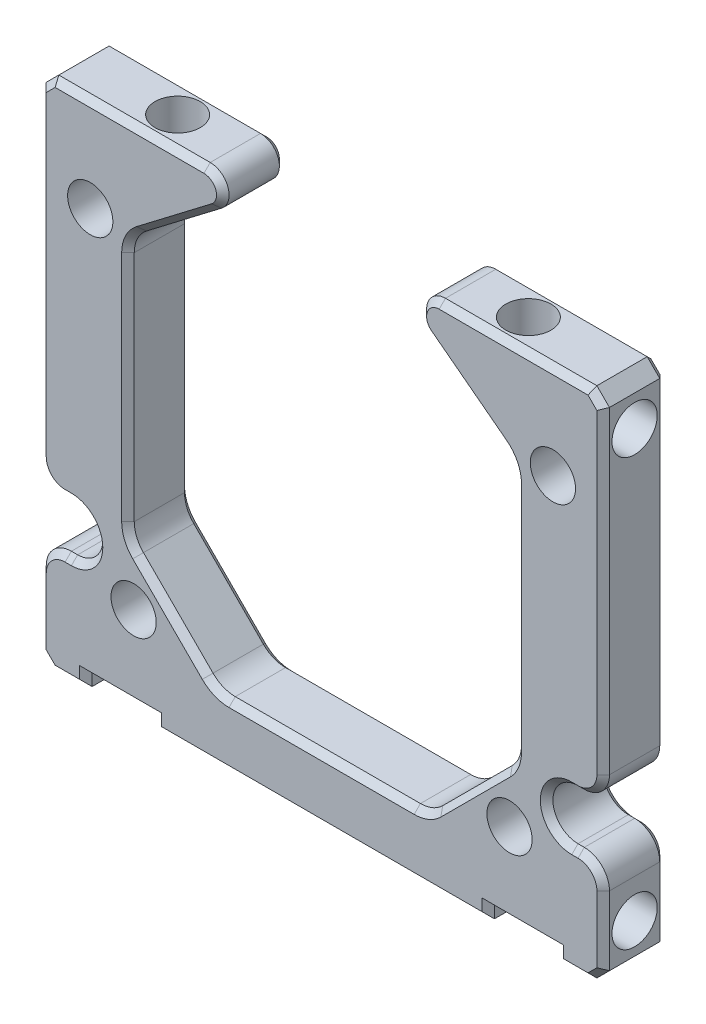
from build123d import *

# Parameters (mm, degrees)
SKETCH2_W               = 44.8
SKETCH2_H               = 40.8
SKETCH2_W_2             = 30.8
SKETCH2_H_2             = 30.8
BOSS_EXTRUDE1_DEPTH     = 5
CHAMFER1_SIZE           = 1
CHAMFER2_SIZE           = 7
SKETCH3_R               = 1.8
CUT_EXTRUDE1_DEPTH      = 31.707002459
SKETCH4_R               = 1.8
CUT_EXTRUDE2_DEPTH      = 5
SKETCH5_R               = 1.8
CUT_EXTRUDE3_DEPTH      = 5
MIRROR2_COPY_1_SKETCH_R = 1.8
MIRROR2_COPY_1_DEPTH    = 31.707002459
MIRROR2_COPY_2_SKETCH_R = 1.8
MIRROR2_COPY_2_DEPTH    = 5
SKETCH8_R               = 1.8
BOSS_EXTRUDE2_DEPTH     = 5
SKETCH9_R               = 1.8
CUT_EXTRUDE6_DEPTH      = 31.707002459
CUT_EXTRUDE4_DEPTH      = 31.707002459
FILLET2_R               = 2
CUT_EXTRUDE5_DEPTH      = 31.707002459
SKETCH10_W              = 5.5
SKETCH10_H              = 0.95
CUT_EXTRUDE7_DEPTH      = 31.707002459
FILLET3_R               = 2.5
FILLET4_R               = 1.5
CHAMFER3_SIZE           = 0.5


with BuildPart() as part:
    # Sketch2 → Boss-Extrude1 (new body)
    with BuildSketch(Plane.XY):
        Rectangle(SKETCH2_W, SKETCH2_H)
        Rectangle(SKETCH2_W_2, SKETCH2_H_2, mode=Mode.SUBTRACT)
    extrude(amount=BOSS_EXTRUDE1_DEPTH)

    # Chamfer1
    chamfer1_edges = [part.edges().sort_by_distance(p)[0] for p in [
        (-22.4, 20.4, 2.5),
        (22.4, 20.4, 2.5),
        (22.4, -20.4, 2.5),
        (-22.4, -20.4, 2.5),
    ]]
    chamfer(chamfer1_edges, length=CHAMFER1_SIZE)

    # Chamfer2
    chamfer2_edges = [part.edges().sort_by_distance(p)[0] for p in [
        (-15.4, 15.4, 2.5),
        (-15.4, -15.4, 2.5),
        (15.4, -15.4, 2.5),
        (15.4, 15.4, 2.5),
    ]]
    chamfer(chamfer2_edges, length=CHAMFER2_SIZE)

    # Sketch3 → Cut-Extrude1 (cut, through all)
    with BuildSketch(Plane.XY.offset(5)):
        with Locations((14.95, 12.95)):
            Circle(SKETCH3_R)
    cut_extrude1 = extrude(amount=-CUT_EXTRUDE1_DEPTH, mode=Mode.SUBTRACT)

    # Sketch4 → Cut-Extrude2 (cut)
    with BuildSketch(Plane(origin=(0, 20.4, 0), x_dir=(1, 0, 0), z_dir=(0, 1, 0))):
        with Locations(Location((13.95, -2.5, 0), (0, 0, 270))):
            Circle(SKETCH4_R)
    cut_extrude2 = extrude(amount=-CUT_EXTRUDE2_DEPTH, mode=Mode.SUBTRACT)

    # Sketch5 → Cut-Extrude3 (cut)
    with BuildSketch(Plane(origin=(22.4, 0, 0), x_dir=(0, 0, -1), z_dir=(1, 0, 0))):
        with Locations(Location((-2.5, 16.95, 0), (0, 0, 90))):
            Circle(SKETCH5_R)
    cut_extrude3 = extrude(amount=-CUT_EXTRUDE3_DEPTH, mode=Mode.SUBTRACT)

    # Mirror1: Cut-Extrude1, Cut-Extrude3 across plane
    add(cut_extrude1.mirror(Plane.ZX), mode=Mode.SUBTRACT)
    add(cut_extrude3.mirror(Plane.ZX), mode=Mode.SUBTRACT)

    # Mirror2: Cut-Extrude1, Cut-Extrude2, Cut-Extrude3 across plane
    add(cut_extrude1.mirror(Plane(origin=(0, 0, 0), x_dir=(0, 0, 1), z_dir=(1, 0, 0))), mode=Mode.SUBTRACT)
    add(cut_extrude2.mirror(Plane(origin=(0, 0, 0), x_dir=(0, 0, 1), z_dir=(1, 0, 0))), mode=Mode.SUBTRACT)
    add(cut_extrude3.mirror(Plane(origin=(0, 0, 0), x_dir=(0, 0, 1), z_dir=(1, 0, 0))), mode=Mode.SUBTRACT)

    # Mirror2 copy 1 sketch → Mirror2 copy 1 (cut, through all)
    with BuildSketch(Plane(origin=(0, 0, 5), x_dir=(-1, 0, 0), z_dir=(0, 0, 1))):
        with Locations((14.95, 12.95)):
            Circle(MIRROR2_COPY_1_SKETCH_R)
    extrude(amount=-MIRROR2_COPY_1_DEPTH, mode=Mode.SUBTRACT)

    # Mirror2 copy 2 sketch → Mirror2 copy 2 (cut)
    with BuildSketch(Plane(origin=(-22.4, 0, 0), x_dir=(0, 0, -1), z_dir=(-1, 0, 0))):
        with Locations(Location((-2.5, 16.95, 0), (0, 0, 90))):
            Circle(MIRROR2_COPY_2_SKETCH_R)
    extrude(amount=-MIRROR2_COPY_2_DEPTH, mode=Mode.SUBTRACT)

    # Sketch8 → Boss-Extrude2 (add)
    with BuildSketch(Plane.XY.offset(5)):
        with Locations((14.95, 12.95)):
            Circle(SKETCH8_R)
        with Locations((-14.95, 12.95)):
            Circle(SKETCH8_R)
    extrude(amount=-BOSS_EXTRUDE2_DEPTH)

    # Sketch9 → Cut-Extrude6 (cut, through all)
    with BuildSketch(Plane.XY.offset(5)):
        with Locations((18.4, 12.95)):
            Circle(SKETCH9_R)
        with Locations((-18.4, 12.95)):
            Circle(SKETCH9_R)
    extrude(amount=-CUT_EXTRUDE6_DEPTH, mode=Mode.SUBTRACT)

    # Sketch6 → Cut-Extrude4 (cut, through all)
    with BuildSketch(Plane.XY.offset(5)):
        with BuildLine():
            Line((22.4, -7.9), (19.9, -7.9))
            ThreePointArc((19.9, -7.9), (17.9, -9.9), (19.9, -11.9))
            Line((19.9, -11.9), (22.4, -11.9))
            Line((22.4, -11.9), (22.4, -7.9))
        make_face()
        with BuildLine():
            Line((-22.4, -11.9), (-19.9, -11.9))
            ThreePointArc((-19.9, -11.9), (-17.9, -9.9), (-19.9, -7.9))
            Line((-19.9, -7.9), (-22.4, -7.9))
            Line((-22.4, -7.9), (-22.4, -11.9))
        make_face()
    extrude(amount=-CUT_EXTRUDE4_DEPTH, mode=Mode.SUBTRACT)

    # Fillet2
    fillet2_edges = [part.edges().sort_by_distance(p)[0] for p in [
        (-22.4, -11.9, 2.5),
        (-22.4, -7.9, 2.5),
        (22.4, -7.9, 2.5),
        (22.4, -11.9, 2.5),
    ]]
    fillet(fillet2_edges, radius=FILLET2_R)

    # Sketch7 → Cut-Extrude5 (cut, through all)
    with BuildSketch(Plane.XY.offset(5)):
        with BuildLine():
            Line((15.4, 8.4), (15.4, 12.4))
            Line((15.4, 12.4), (7.887250822, 18.133986378))
            ThreePointArc((7.887250822, 18.133986378), (5.658222966, 19.504038315), (3.2, 20.4))
            Line((3.2, 20.4), (-3.2, 20.4))
            ThreePointArc((-3.2, 20.4), (-5.658222966, 19.504038315), (-7.887250822, 18.133986378))
            Line((-7.887250822, 18.133986378), (-15.4, 12.4))
            Line((-15.4, 12.4), (-15.4, 8.4))
            Line((-15.4, 8.4), (-8.4, 15.4))
            Line((-8.4, 15.4), (8.4, 15.4))
            Line((8.4, 15.4), (15.4, 8.4))
        make_face()
    extrude(amount=-CUT_EXTRUDE5_DEPTH, mode=Mode.SUBTRACT)

    # Sketch10 → Cut-Extrude7 (cut, through all)
    with BuildSketch(Plane.XY.offset(5)):
        with Locations((-16, -19.925)):
            Rectangle(SKETCH10_W, SKETCH10_H)
        with Locations((16, -19.925)):
            Rectangle(SKETCH10_W, SKETCH10_H)
    extrude(amount=-CUT_EXTRUDE7_DEPTH, mode=Mode.SUBTRACT)

    # Fillet3
    fillet3_edges = [part.edges().sort_by_distance(p)[0] for p in [
        (-15.4, 12.4, 2.5),
        (15.4, 12.4, 2.5),
        (-15.4, -8.4, 2.5),
        (8.4, -15.4, 2.5),
        (-8.4, -15.4, 2.5),
        (15.4, -8.4, 2.5),
    ]]
    fillet(fillet3_edges, radius=FILLET3_R)

    # Fillet4
    fillet4_edges = [part.edges().sort_by_distance(p)[0] for p in [
        (-3.2, 20.4, 2.5),
        (3.2, 20.4, 2.5),
    ]]
    fillet(fillet4_edges, radius=FILLET4_R)

    # Chamfer3
    chamfer3_edges = [part.edges().sort_by_distance(p)[0] for p in [
        (-17.9, -9.9, 0),
        (-20.15, -11.9, 5),
        (-20.15, -11.9, 0),
        (-17.9, -9.9, 5),
        (20.15, -11.9, 0),
        (17.9, -9.9, 0),
        (17.9, -9.9, 5),
        (20.15, -11.9, 5),
        (20.15, -7.9, 5),
        (22.4, 6.75, 5),
        (-20.15, -7.9, 5),
        (-22.4, -16.65, 5),
        (21.814213562, -12.485786438, 5),
        (21.814213562, -7.314213562, 5),
        (-21.814213562, -12.485786438, 5),
        (-21.814213562, -7.314213562, 5),
        (-20.15, -7.9, 0),
        (22.4, 6.75, 0),
        (20.15, -7.9, 0),
        (-22.4, -16.65, 0),
        (21.814213562, -12.485786438, 0),
        (21.814213562, -7.314213562, 0),
        (-21.814213562, -12.485786438, 0),
        (-21.814213562, -7.314213562, 0),
        (0, -20.4, 5),
        (0, -20.4, 0),
        (-18.75, -19.925, 0),
        (-16, -19.45, 0),
        (-13.25, -19.925, 0),
        (-18.75, -19.925, 5),
        (-13.25, -19.925, 5),
        (-16, -19.45, 5),
        (20.075, -20.4, 5),
        (20.075, -20.4, 0),
        (13.25, -19.925, 0),
        (16, -19.45, 0),
        (18.75, -19.925, 0),
        (13.25, -19.925, 5),
        (18.75, -19.925, 5),
        (16, -19.45, 5),
        (0, -15.4, 0),
        (0, -15.4, 5),
        (11.9, -11.9, 5),
        (11.9, -11.9, 0),
        (-11.9, -11.9, 5),
        (-11.9, -11.9, 0),
        (-20.075, -20.4, 0),
        (-15.4, 1.899328314, 5),
        (-15.4, 1.899328314, 0),
        (15.4, 1.899328314, 0),
        (15.4, 1.899328314, 5),
        (-20.075, -20.4, 5),
        (11.431332504, 15.429022375, 5),
        (11.431332504, 15.429022375, 0),
        (8.321174675, -15.209698831, 0),
        (8.321174675, -15.209698831, 5),
        (-8.321174675, -15.209698831, 5),
        (-8.321174675, -15.209698831, 0),
        (-15.209698831, -8.321174675, 0),
        (-15.209698831, -8.321174675, 5),
        (15.209698831, -8.321174675, 5),
        (15.209698831, -8.321174675, 0),
        (-15.140752944, 12.271737283, 5),
        (-15.140752944, 12.271737283, 0),
        (15.140752944, 12.271737283, 5),
        (15.140752944, 12.271737283, 0),
        (-22.4, 6.75, 0),
        (15.377976703, 20.4, 0),
        (22.4, -16.65, 0),
        (-11.431332504, 15.429022375, 5),
        (-11.431332504, 15.429022375, 0),
        (-15.377976703, 20.4, 5),
        (7.934937122, 19.380325637, 5),
        (-7.934937122, 19.380325637, 5),
        (-21.9, 19.9, 0),
        (-15.377976703, 20.4, 0),
        (7.934937122, 19.380325637, 0),
        (-7.934937122, 19.380325637, 0),
        (21.9, 19.9, 0),
        (21.9, -19.9, 0),
        (-21.9, -19.9, 0),
        (-22.4, 6.75, 5),
        (22.4, -16.65, 5),
        (15.377976703, 20.4, 5),
        (-21.9, 19.9, 5),
        (21.9, 19.9, 5),
        (21.9, -19.9, 5),
        (-21.9, -19.9, 5),
    ]]
    chamfer(chamfer3_edges, length=CHAMFER3_SIZE)


solid = part.part
